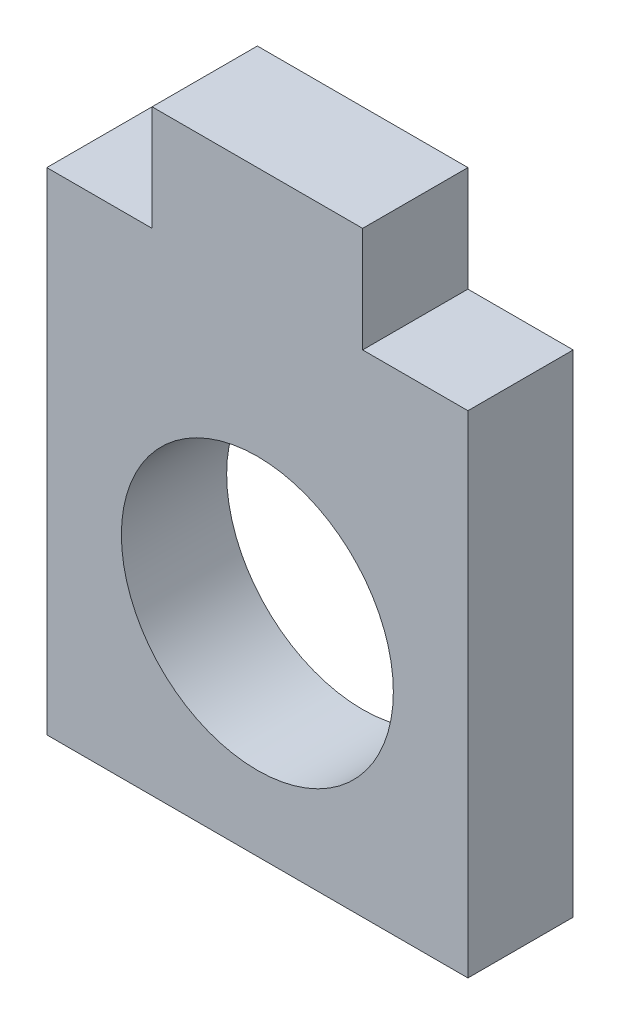
from build123d import *

# Parameters (mm, degrees)
SKETCH1_W           = 12
SKETCH1_H           = 14
BOSS_EXTRUDE1_DEPTH = 3
SKETCH2_R           = 3.875
CUT_EXTRUDE1_DEPTH  = 3
SKETCH3_W           = 6
SKETCH3_H           = 3
BOSS_EXTRUDE2_DEPTH = 3


with BuildPart() as part:
    # Sketch1 → Boss-Extrude1 (new body)
    with BuildSketch(Plane.XY):
        with Locations((0, -1)):
            Rectangle(SKETCH1_W, SKETCH1_H)
    extrude(amount=BOSS_EXTRUDE1_DEPTH)

    # Sketch2 → Cut-Extrude1 (cut)
    with BuildSketch(Plane.XY.offset(3)):
        with Locations((0, -2)):
            Circle(SKETCH2_R)
    extrude(amount=-CUT_EXTRUDE1_DEPTH, mode=Mode.SUBTRACT)

    # Sketch3 → Boss-Extrude2 (add)
    with BuildSketch(Plane(origin=(0, 6, 0), x_dir=(1, 0, 0), z_dir=(0, 1, 0))):
        with Locations((0, -1.5)):
            Rectangle(SKETCH3_W, SKETCH3_H)
    extrude(amount=BOSS_EXTRUDE2_DEPTH)


solid = part.part
